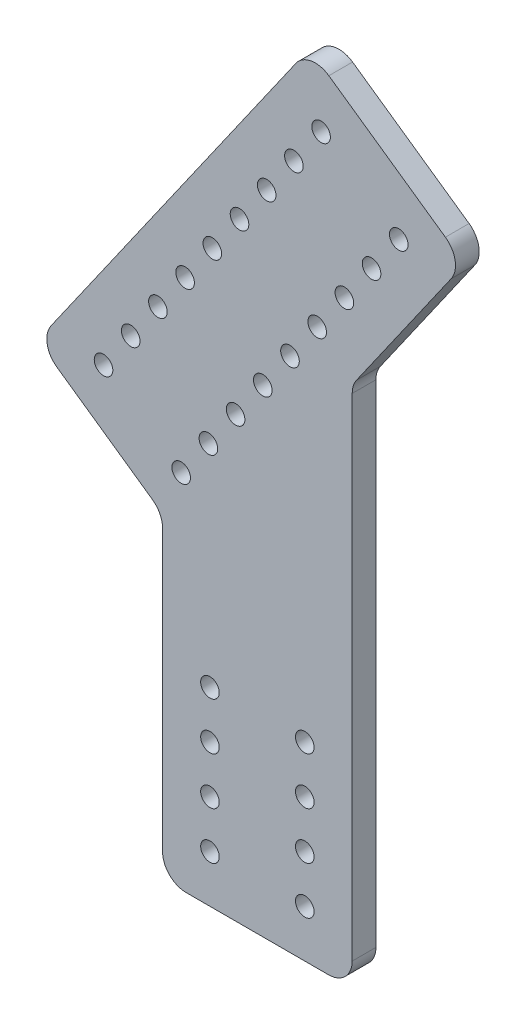
from build123d import *

# Parameters (mm, degrees)
BOSS_EXTRUDE1_DEPTH = 6.35
SKETCH2_R           = 2.4892
CUT_EXTRUDE1_DEPTH  = 7.35
BOSS_EXTRUDE2_DEPTH = 6.35
SKETCH2_4_R         = 2.4892
CUT_EXTRUDE2_DEPTH  = 7.35
FILLET1_R           = 6.35


with BuildPart() as part:
    # Sketch1 → Boss-Extrude1 (new body)
    with BuildSketch(Plane.XY):
        Polygon((0, 156.050081258), (50.8, 228.6), (50.8, 0), (0, 0), align=None)
    extrude(amount=BOSS_EXTRUDE1_DEPTH)

    # Sketch2 → Cut-Extrude1 (cut, through all)
    with BuildSketch(Plane(origin=(0, 0, 0), x_dir=(-1, 0, 0), z_dir=(0, 0, -1))):
        Polygon((-39.347389129, 212.243976613), (-50.8, 228.6), (-50.8, 204.224772149), align=None)
        with Locations((-42.46619935, 194.556324909)):
            Circle(SKETCH2_R)
        with Locations((-35.181778608, 184.153093946)):
            Circle(SKETCH2_R)
        with Locations((-27.897357867, 173.749862984)):
            Circle(SKETCH2_R)
        with Locations((-20.612937125, 163.346632021)):
            Circle(SKETCH2_R)
        with Locations((-13.328516383, 152.943401059)):
            Circle(SKETCH2_R)
        with Locations((-6.044095642, 142.540170097)):
            Circle(SKETCH2_R)
        with Locations((-26.850557567, 127.971328613)):
            Circle(SKETCH2_R)
        with Locations((-19.566136825, 117.568097651)):
            Circle(SKETCH2_R)
        with Locations((-12.281716083, 107.164866688)):
            Circle(SKETCH2_R)
        with Locations((-34.134978308, 138.374559576)):
            Circle(SKETCH2_R)
        with Locations((-41.41939905, 148.777790538)):
            Circle(SKETCH2_R)
        with Locations((-4.997295342, 96.761635726)):
            Circle(SKETCH2_R)
        with Locations((-38.1, 12.7)):
            Circle(SKETCH2_R)
        with Locations((-12.7, 12.7)):
            Circle(SKETCH2_R)
        with Locations((-12.7, 25.4)):
            Circle(SKETCH2_R)
        with Locations((-38.1, 25.4)):
            Circle(SKETCH2_R)
        with Locations((-38.1, 38.1)):
            Circle(SKETCH2_R)
        with Locations((-12.7, 38.1)):
            Circle(SKETCH2_R)
        with Locations((-12.7, 50.8)):
            Circle(SKETCH2_R)
        with Locations((-38.1, 50.8)):
            Circle(SKETCH2_R)
    extrude(amount=-CUT_EXTRUDE1_DEPTH, mode=Mode.SUBTRACT)

    # Sketch3 → Boss-Extrude2 (add)
    with BuildSketch(Plane.XY):
        Polygon((0, 156.050081258), (-33.496818287, 108.211666988), (0, 84.756942318), align=None)
        Polygon((50.8, 204.224772149), (50.8, 140.032902782), (80.960312979, 183.106293646), align=None)
    extrude(amount=BOSS_EXTRUDE2_DEPTH)

    # Sketch2_4 → Cut-Extrude2 (cut, through all)
    with BuildSketch(Plane(origin=(0, 0, 0), x_dir=(-1, 0, 0), z_dir=(0, 0, -1))):
        with Locations((15.809166583, 111.330477209)):
            Circle(SKETCH2_4_R)
        with Locations((8.524745841, 121.733708172)):
            Circle(SKETCH2_4_R)
        with BuildLine():
            ThreePointArc((3.7295251, 132.136939134), (2.487060718, 134.291415158), (0, 134.295112039))
            Line((0, 134.295112039), (0, 129.978766229))
            ThreePointArc((0, 129.978766229), (2.487060718, 129.98246311), (3.7295251, 132.136939134))
        make_face()
        with BuildLine():
            Line((0, 129.978766229), (0, 134.295112039))
            ThreePointArc((0, 134.295112039), (-1.2488749, 132.136939134), (0, 129.978766229))
        make_face()
        with BuildLine():
            ThreePointArc((-46.214619792, 159.181021501), (-48.004425459, 161.569946825), (-50.8, 160.523461508))
            Line((-50.8, 160.523461508), (-50.8, 157.838581493))
            ThreePointArc((-50.8, 157.838581493), (-48.004425459, 156.792096176), (-46.214619792, 159.181021501))
        make_face()
        with BuildLine():
            Line((-50.8, 157.838581493), (-50.8, 160.523461508))
            ThreePointArc((-50.8, 160.523461508), (-51.193019792, 159.181021501), (-50.8, 157.838581493))
        make_face()
        with Locations((-55.988240533, 169.584252463)):
            Circle(SKETCH2_4_R)
        with Locations((-63.272661275, 179.987483426)):
            Circle(SKETCH2_4_R)
    extrude(amount=-CUT_EXTRUDE2_DEPTH, mode=Mode.SUBTRACT)

    # Fillet1
    fillet1_edges = [part.edges().sort_by_distance(p)[0] for p in [
        (-33.496818287, 108.211666988, 3.175),
        (0, 84.756942318, 3.175),
        (50.8, 140.032902782, 3.175),
        (80.960312979, 183.106293646, 3.175),
        (39.347389129, 212.243976613, 3.175),
        (50.8, 0, 3.175),
        (0, 0, 3.175),
    ]]
    fillet(fillet1_edges, radius=FILLET1_R)


solid = part.part
